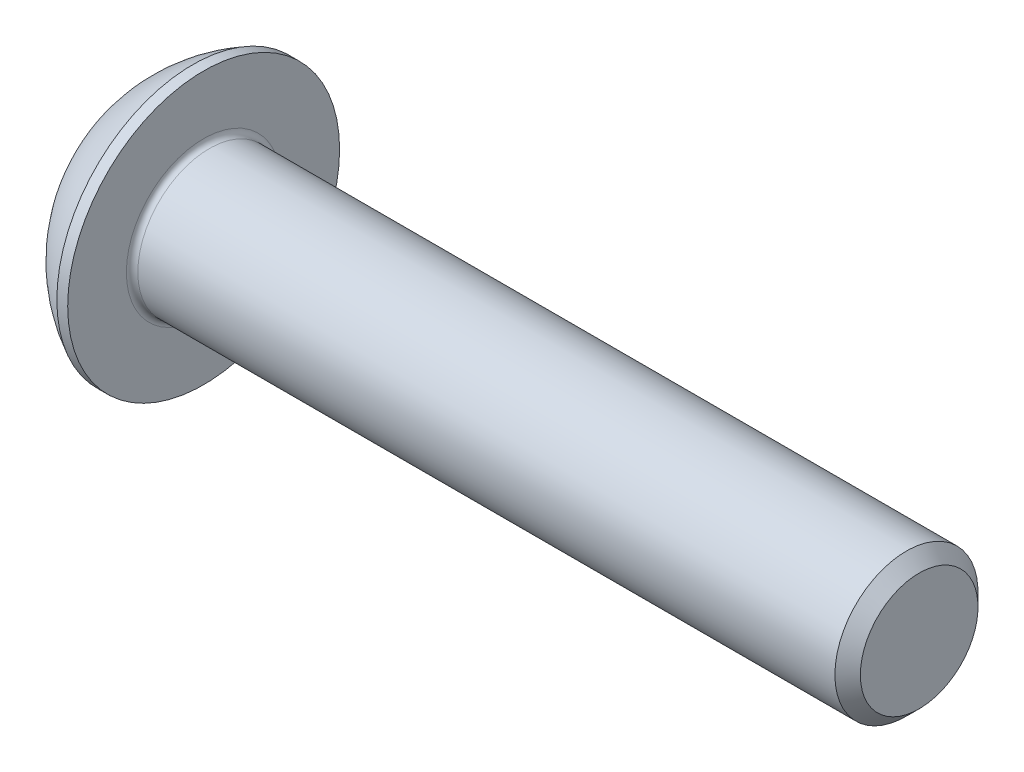
from build123d import *

# Parameters (mm, degrees)
FILLET1_R   = 0.2
HEX_2_DEPTH = 1.56


with BuildPart() as part:
    # BodySke → BaseBody (revolve)
    with BuildSketch(Plane.XY):
        with BuildLine():
            Line((27.75, 0), (27.75, 2.055))
            Line((27.75, 2.055), (27.305, 2.5))
            Line((27.305, 2.5), (2.75, 2.5))
            Line((2.75, 2.5), (2.75, 4.75))
            Line((2.75, 4.75), (2.37, 4.75))
            ThreePointArc((2.37, 4.75), (0.992680215, 3.754414901), (0, 2.375))
            Line((0, 2.375), (0, 0))
            Line((0, 0), (27.75, 0))
        make_face()
    revolve(axis=Axis((0, 0, 0), (1, 0, 0)))

    # Fillet1
    fillet1_edges = [part.edges().sort_by_distance(p)[0] for p in [
        (2.75, -2.5, 0),
    ]]
    fillet(fillet1_edges, radius=FILLET1_R)

    # Sketch2 → PreBroach (revolve, cut)
    with BuildSketch(Plane.XY):
        Polygon((0, 1.5), (1.56, 1.5), (2.426025404, 0), (0, 0), align=None)
    revolve(axis=Axis((0, 0, 0), (1, 0, 0)), mode=Mode.SUBTRACT)

    # Sketch3 → Hex 2 (cut)
    with BuildSketch(Plane(origin=(0, 0, 0), x_dir=(0, 0, -1), z_dir=(1, 0, 0))):
        Polygon((-1.5, -0.866025404), (-1.5, 0.866025404), (0, 1.732050808), (1.5, 0.866025404), (1.5, -0.866025404), (0, -1.732050808), align=None)
    extrude(amount=HEX_2_DEPTH, mode=Mode.SUBTRACT)


solid = part.part
